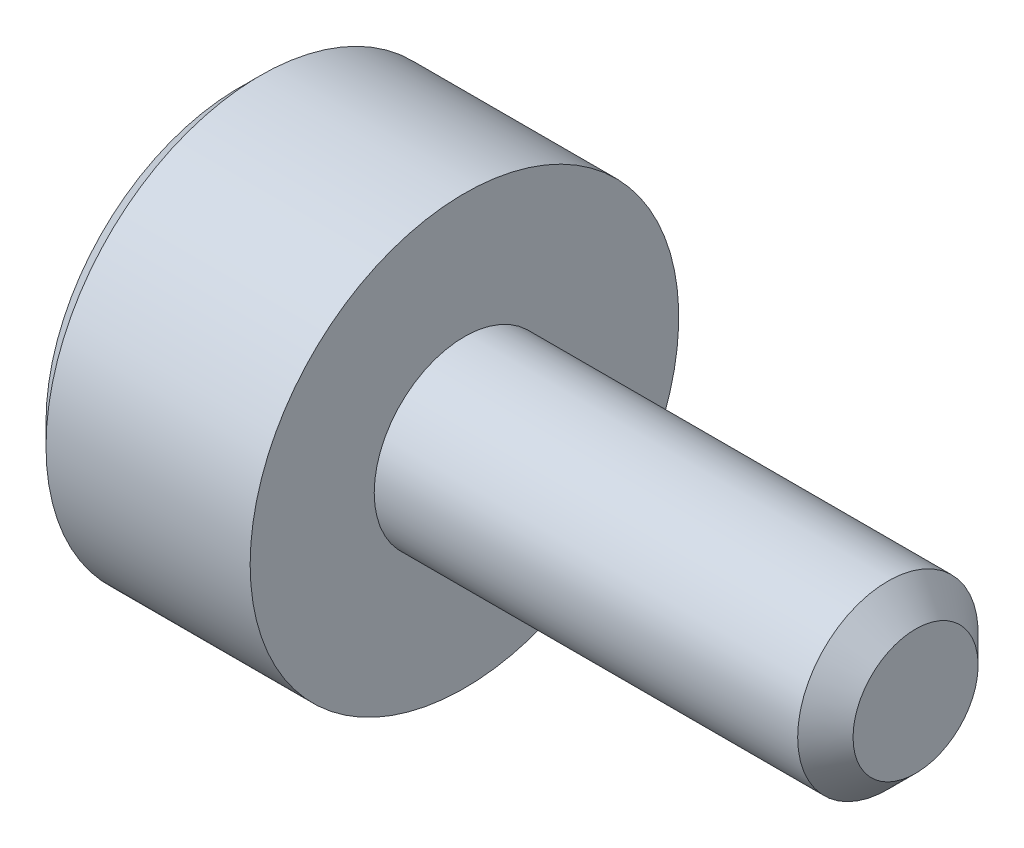
from build123d import *

# Parameters (mm, degrees)
CUT_EXTRUDE1_DEPTH = 0.8


with BuildPart() as part:
    # Sketch1 → Revolve1 (revolve)
    with BuildSketch(Plane.XY):
        Polygon((-2, 0), (-2, 1.71), (-1.81, 1.9), (0, 1.9), (0, 0.8), (3.7545, 0.8), (4, 0.5545), (4, 0), align=None)
    revolve(axis=Axis((4, 0, 0), (-1, 0, 0)))

    # Sketch2 → Cut-Extrude1 (cut)
    with BuildSketch(Plane(origin=(-2, 0, 0), x_dir=(0, 0, -1), z_dir=(1, 0, 0))):
        Polygon((-0.75, -0.433012702), (0, -0.866025404), (0.75, -0.433012702), (0.75, 0.433012702), (0, 0.866025404), (-0.75, 0.433012702), align=None)
    extrude(amount=CUT_EXTRUDE1_DEPTH, mode=Mode.SUBTRACT)


solid = part.part
